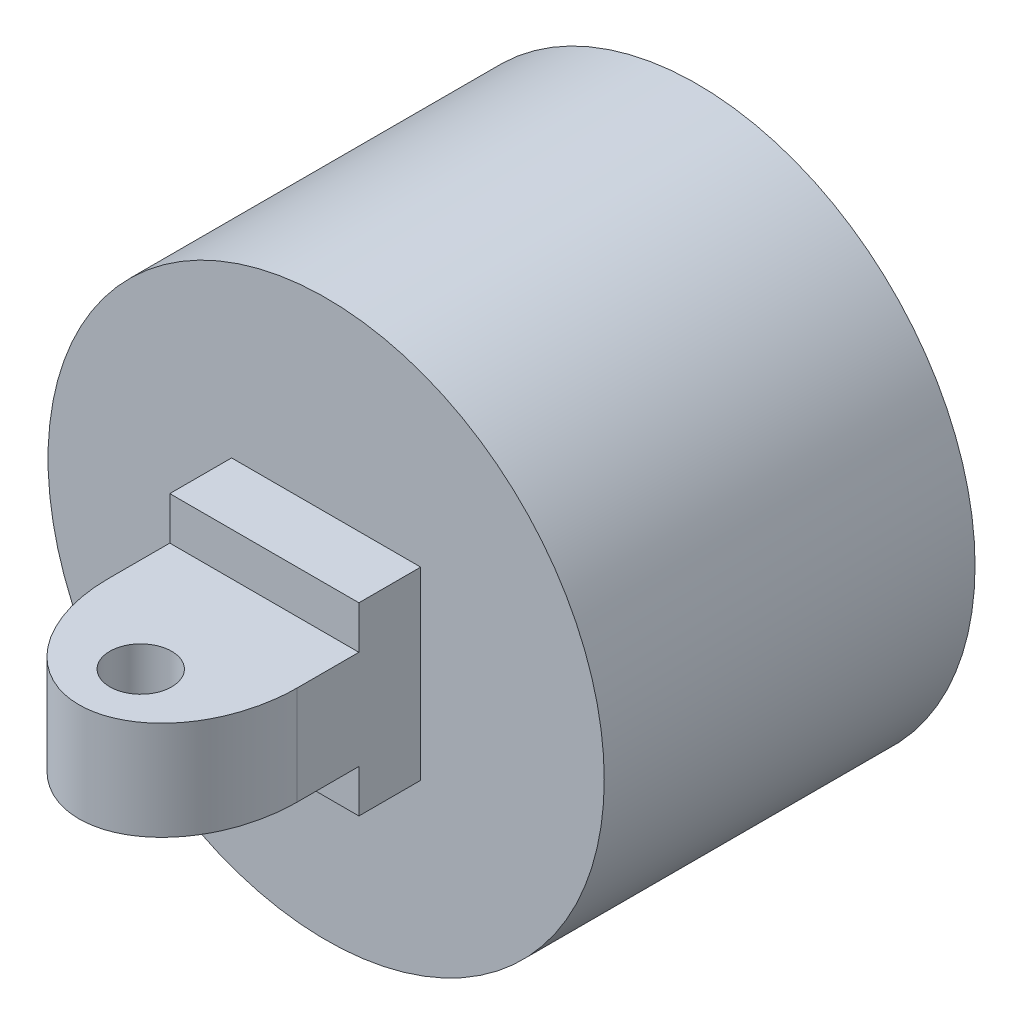
from build123d import *

# Parameters (mm, degrees)
SKETCH1_R               = 22.5
BOSS_EXTRUDE1_DEPTH     = 30
SKETCH2_R               = 7.5
SKETCH2_W               = 3
SKETCH2_H               = 30
SKETCH2_W_2             = 30
SKETCH2_H_2             = 3
CUT_EXTRUDE1_DEPTH      = 10
SKETCH3_W               = 15.299534312
SKETCH3_H               = 14.93812799
BOSS_EXTRUDE2_DEPTH     = 20
CUT_EXTRUDE2_DEPTH      = 20
SKETCH5_R               = 2.5
CUT_EXTRUDE4_DEPTH      = 20
SKETCH10_W              = 15.299534312
SKETCH10_H              = 5
CUT_EXTRUDE5_DEPTH      = 23
CUT_EXTRUDE5_DEPTH_BACK = 11.4
SKETCH11_W              = 15.299534312
SKETCH11_H              = 5
SKETCH11_R              = 2.5
BOSS_EXTRUDE3_DEPTH     = 8
SKETCH13_W              = 10
SKETCH13_H              = 3.47
SKETCH13_W_2            = 5
CUT_EXTRUDE6_DEPTH      = 21


with BuildPart() as part:
    # Sketch1 → Boss-Extrude1 (new body)
    with BuildSketch(Plane.XY):
        Circle(SKETCH1_R)
    extrude(amount=BOSS_EXTRUDE1_DEPTH)

    # Sketch2 → Cut-Extrude1 (cut)
    with BuildSketch(Plane(origin=(0, 0, 0), x_dir=(-1, 0, 0), z_dir=(0, 0, -1))):
        Circle(SKETCH2_R)
        Rectangle(SKETCH2_W, SKETCH2_H)
        Rectangle(SKETCH2_W_2, SKETCH2_H_2)
    extrude(amount=-CUT_EXTRUDE1_DEPTH, mode=Mode.SUBTRACT)

    # Sketch3 → Boss-Extrude2 (add)
    with BuildSketch(Plane.XY.offset(30)):
        Rectangle(SKETCH3_W, SKETCH3_H)
    extrude(amount=BOSS_EXTRUDE2_DEPTH)

    # Sketch4 → Cut-Extrude2 (cut)
    with BuildSketch(Plane.ZY.offset(7.649767156)):
        Polygon((40, 4), (50, 4), (50, 0), (50, -4), (40, -4), (35, -4), (35, 4), align=None)
    extrude(amount=-CUT_EXTRUDE2_DEPTH, mode=Mode.SUBTRACT)

    # Sketch5 → Cut-Extrude4 (cut)
    with BuildSketch(Plane(origin=(0, 7.469063995, 0), x_dir=(1, 0, 0), z_dir=(0, 1, 0))):
        with Locations((0, -45)):
            Circle(SKETCH5_R)
        with BuildLine():
            Line((7.649767156, -50), (7.649767156, -40))
            add(Edge.make_bspline(
                [(0, -50), (7.649767156, -50), (7.649767156, -40)],
                knots=[3.141592654, 3.141592654, 3.141592654, 4.71238898, 4.71238898, 4.71238898], degree=2, weights=[1, 0.707106781, 1]))
            Line((0, -50), (7.649767156, -50))
        make_face()
        with BuildLine():
            Line((-7.649767156, -50), (0, -50))
            add(Edge.make_bspline(
                [(-7.649767156, -40), (-7.649767156, -50), (0, -50)],
                knots=[1.570796327, 1.570796327, 1.570796327, 3.141592654, 3.141592654, 3.141592654], degree=2, weights=[1, 0.707106781, 1]))
            Line((-7.649767156, -40), (-7.649767156, -50))
        make_face()
    extrude(amount=-CUT_EXTRUDE4_DEPTH, mode=Mode.SUBTRACT)

    # Sketch10 → Cut-Extrude5 (cut, two sides)
    with BuildSketch(Plane(origin=(0, 7.469063995, 0), x_dir=(1, 0, 0), z_dir=(0, 1, 0))) as cut_extrude5_sk:
        with Locations((0, -37.5)):
            Rectangle(SKETCH10_W, SKETCH10_H)
        with BuildLine():
            Line((7.649767156, -40), (-7.649767156, -40))
            add(Edge.make_bspline(
                [(-7.649767156, -40), (-7.649767156, -50), (0, -50), (7.649767156, -50), (7.649767156, -40)],
                knots=[4.71238898, 4.71238898, 4.71238898, 6.283185307, 6.283185307, 7.853981634, 7.853981634, 7.853981634], degree=2, weights=[1, 0.707106781, 1, 0.707106781, 1]))
        make_face()
    extrude(amount=CUT_EXTRUDE5_DEPTH, mode=Mode.SUBTRACT)
    extrude(cut_extrude5_sk.sketch, amount=-CUT_EXTRUDE5_DEPTH_BACK, mode=Mode.SUBTRACT)

    # Sketch11 → Boss-Extrude3 (add)
    with BuildSketch(Plane(origin=(0, -4, 0), x_dir=(1, 0, 0), z_dir=(0, 1, 0))):
        with Locations((0, -37.5)):
            Rectangle(SKETCH11_W, SKETCH11_H)
        with BuildLine():
            Line((7.649767156, -40), (-7.649767156, -40))
            add(Edge.make_bspline(
                [(-7.649767156, -40), (-7.649767156, -50), (0, -50), (7.649767156, -50), (7.649767156, -40)],
                knots=[4.71238898, 4.71238898, 4.71238898, 6.283185307, 6.283185307, 7.853981634, 7.853981634, 7.853981634], degree=2, weights=[1, 0.707106781, 1, 0.707106781, 1]))
        make_face()
        with Locations((0, -45)):
            Circle(SKETCH11_R, mode=Mode.SUBTRACT)
    extrude(amount=BOSS_EXTRUDE3_DEPTH)

    # Sketch13 → Cut-Extrude6 (cut)
    with BuildSketch(Plane.ZY.offset(7.649767156)):
        with Locations((45, -5.734063995)):
            Rectangle(SKETCH13_W, SKETCH13_H)
        with Locations((37.5, -5.734063995)):
            Rectangle(SKETCH13_W_2, SKETCH13_H)
    extrude(amount=-CUT_EXTRUDE6_DEPTH, mode=Mode.SUBTRACT)


solid = part.part
